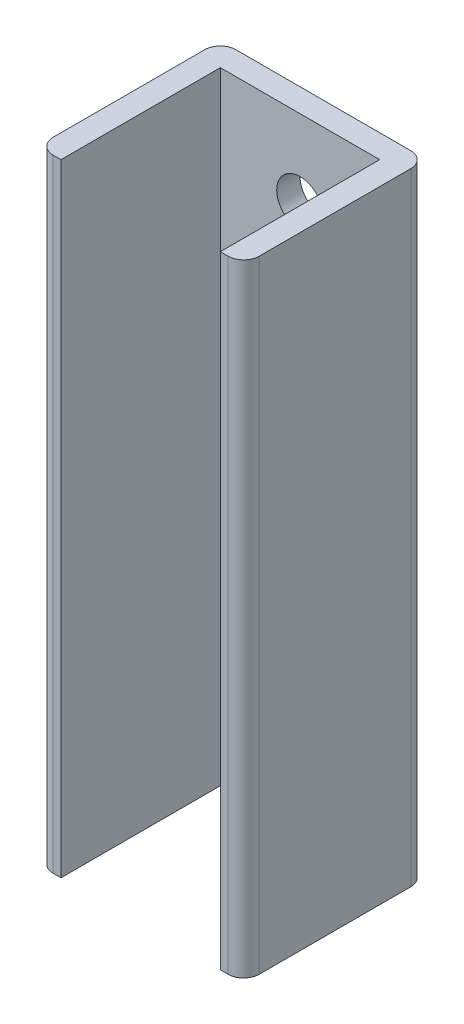
from build123d import *

# Parameters (mm, degrees)
BOSS_EXTRUDE1_DEPTH = 80
SKETCH3_R           = 3
CUT_EXTRUDE1_DEPTH  = 26


with BuildPart() as part:
    # Sketch1 → Boss-Extrude1 (new body)
    with BuildSketch(Plane(origin=(0, 0, 0), x_dir=(1, 0, 0), z_dir=(0, 1, 0))):
        with BuildLine():
            Line((11.25, 13.25), (-11.25, 13.25))
            ThreePointArc((-11.25, 13.25), (-12.664213562, 12.664213562), (-13.25, 11.25))
            Line((-13.25, 11.25), (-13.25, -8.25))
            ThreePointArc((-13.25, -8.25), (-12.664213562, -9.664213562), (-11.25, -10.25))
            Line((-11.25, -10.25), (-10.25, -10.25))
            Line((-10.25, -10.25), (-10.25, 10.25))
            Line((-10.25, 10.25), (10.25, 10.25))
            Line((10.25, 10.25), (10.25, -10.25))
            Line((10.25, -10.25), (11.25, -10.25))
            ThreePointArc((11.25, -10.25), (12.664213562, -9.664213562), (13.25, -8.25))
            Line((13.25, -8.25), (13.25, 11.25))
            ThreePointArc((13.25, 11.25), (12.664213562, 12.664213562), (11.25, 13.25))
        make_face()
    extrude(amount=BOSS_EXTRUDE1_DEPTH)

    # Sketch3 → Cut-Extrude1 (cut)
    with BuildSketch(Plane(origin=(0, 0, -13.25), x_dir=(-1, 0, 0), z_dir=(0, 0, -1))):
        with Locations((0, 70)):
            Circle(SKETCH3_R)
        with Locations((0, 10)):
            Circle(SKETCH3_R)
    extrude(amount=-CUT_EXTRUDE1_DEPTH, mode=Mode.SUBTRACT)


solid = part.part
